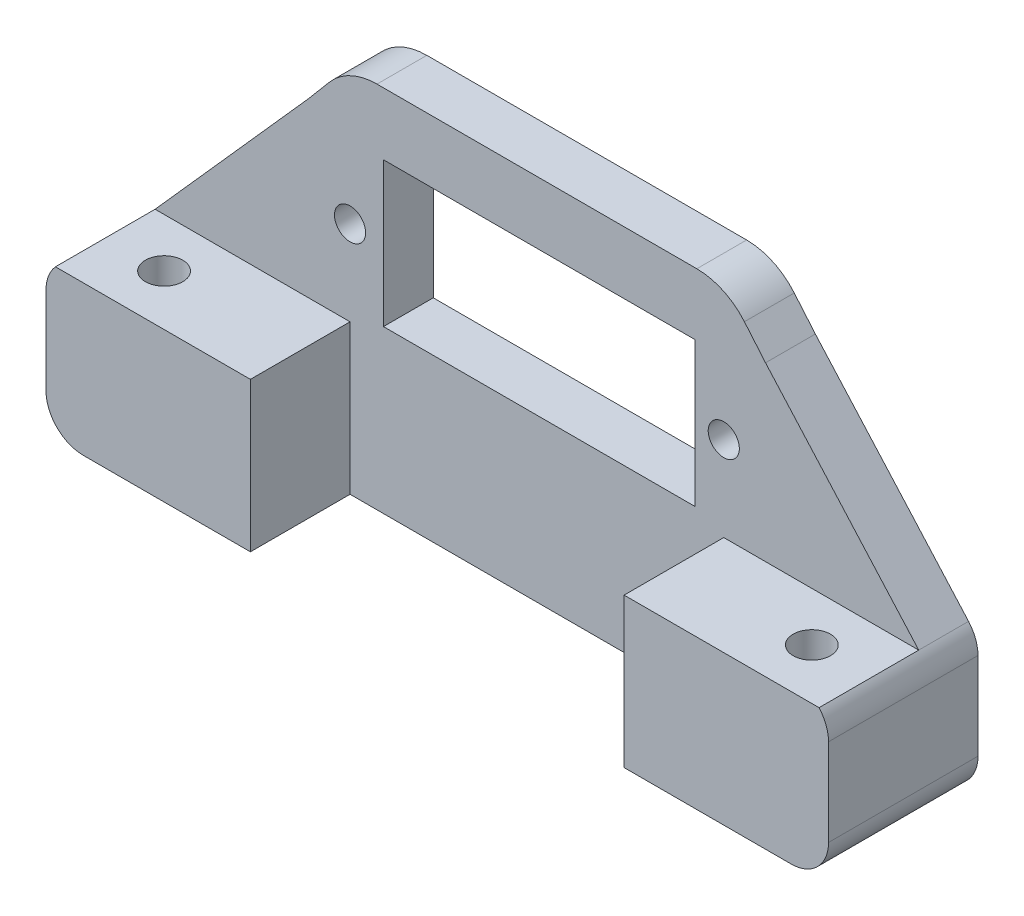
from build123d import *

# Parameters (mm, degrees)
SKETCH_1_W          = 25
SKETCH_1_H          = 11.6
SKETCH_1_R          = 1.25
EXTRUDE_2_DEPTH     = 4
EXTRUDE_3_DEPTH     = 12
SKETCH_2_R          = 1.5
CUT_EXTRUDE_1_DEPTH = 64.671080162


with BuildPart() as part:
    # 草图1 → 凸台-拉伸2 (new body)
    with BuildSketch(Plane.XY):
        with BuildLine():
            ThreePointArc((15.754115944, 0), (13.648249367, -0.465099124), (11.934157469, -1.773869616))
            Line((11.934157469, -1.773869616), (10.238822763, -3.781261572))
            Line((10.238822763, -3.781261572), (-2.059131374, -17.607))
            Line((-2.059131374, -17.607), (13.591371981, -17.607))
            Line((13.591371981, -17.607), (13.591371981, -29.6))
            Line((13.591371981, -29.6), (43.591371981, -29.6))
            Line((43.591371981, -29.6), (43.591371981, -17.607))
            Line((43.591371981, -17.607), (59.241875336, -17.607))
            Line((59.241875336, -17.607), (46.9439212, -3.781261572))
            Line((46.9439212, -3.781261572), (45.248586493, -1.773869616))
            ThreePointArc((45.248586493, -1.773869616), (43.534494596, -0.465099124), (41.428628019, 0))
            Line((41.428628019, 0), (15.754115944, 0))
        make_face()
        with Locations((28.771371981, -10.8)):
            Rectangle(SKETCH_1_W, SKETCH_1_H, mode=Mode.SUBTRACT)
        with Locations((13.591371981, -10.8)):
            Circle(SKETCH_1_R, mode=Mode.SUBTRACT)
        with Locations((43.591371981, -10.8)):
            Circle(SKETCH_1_R, mode=Mode.SUBTRACT)
    extrude(amount=EXTRUDE_2_DEPTH)

    # 草图1<4> → 凸台-拉伸3 (add)
    with BuildSketch(Plane.XY):
        with BuildLine():
            Line((13.591371981, -17.607), (-2.059131374, -17.607))
            ThreePointArc((-2.059131374, -17.607), (-2.621323899, -18.533838426), (-2.817256037, -19.6))
            Line((-2.817256037, -19.6), (-2.817256037, -26.6))
            ThreePointArc((-2.817256037, -26.6), (-1.938576381, -28.721320344), (0.182743963, -29.6))
            Line((0.182743963, -29.6), (13.591371981, -29.6))
            Line((13.591371981, -29.6), (13.591371981, -17.607))
        make_face()
        with BuildLine():
            ThreePointArc((60, -19.6), (59.804067862, -18.533838426), (59.241875336, -17.607))
            Line((59.241875336, -17.607), (43.591371981, -17.607))
            Line((43.591371981, -17.607), (43.591371981, -29.6))
            Line((43.591371981, -29.6), (57, -29.6))
            ThreePointArc((57, -29.6), (59.121320344, -28.721320344), (60, -26.6))
            Line((60, -26.6), (60, -19.6))
        make_face()
    extrude(amount=EXTRUDE_3_DEPTH)

    # 草图2 → 切除-拉伸1 (cut, through all)
    with BuildSketch(Plane(origin=(0, -17.607, 0), x_dir=(1, 0, 0), z_dir=(0, 1, 0))):
        with Locations((2.591371981, -7.929255465)):
            Circle(SKETCH_2_R)
        with Locations((54.591371981, -7.929255465)):
            Circle(SKETCH_2_R)
    extrude(amount=-CUT_EXTRUDE_1_DEPTH, mode=Mode.SUBTRACT)


solid = part.part
